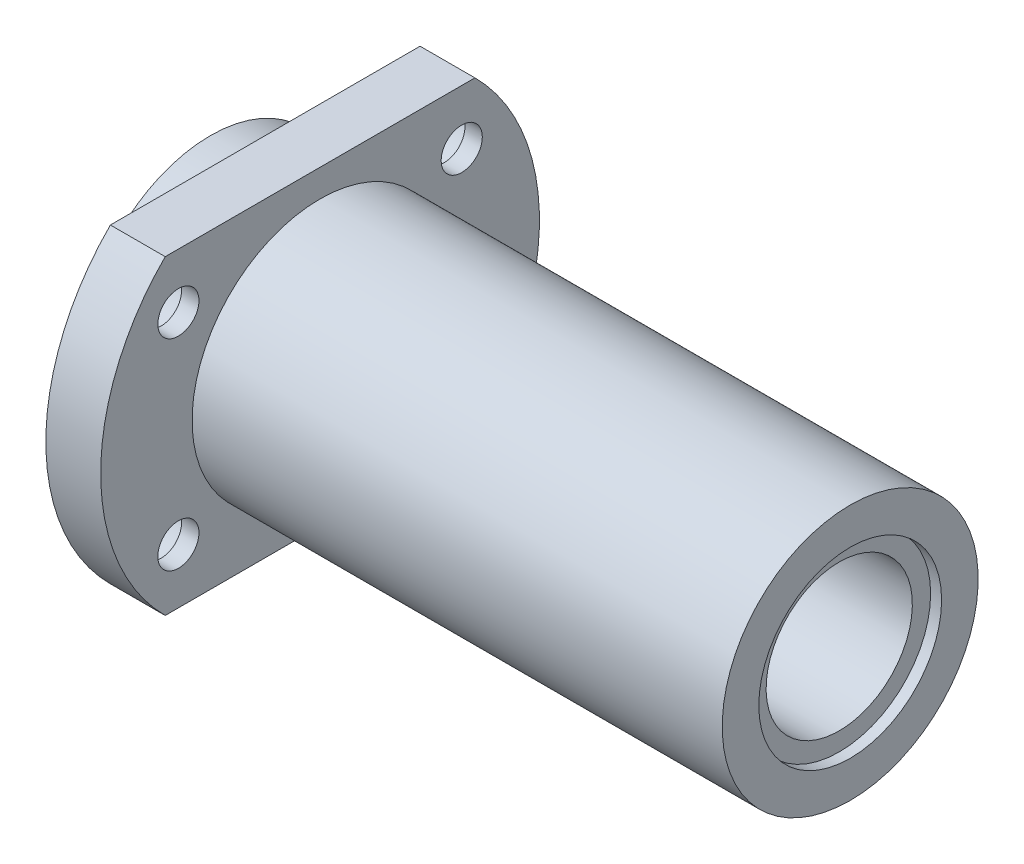
from build123d import *

# Parameters (mm, degrees)
SKETCH_4_R          = 2.25
CUT_EXTRUDE_1_DEPTH = 73.443081105
SKETCH_5_R          = 3.75
CUT_EXTRUDE_4_DEPTH = 4.1
CUT_EXTRUDE_3_DEPTH = 73.443081105


with BuildPart() as part:
    # 草图1 → 旋转1 (revolve)
    with BuildSketch(Plane.XY):
        Polygon((12, 24), (6, 24), (6, 14), (0, 14), (0, 10), (1.2, 10), (1.2, 8), (68.8, 8), (68.8, 10), (70, 10), (70, 14), (12, 14), align=None)
    revolve(axis=Axis((70, 0, 0), (-1, 0, 0)))

    # 草图4 → 切除-拉伸1 (cut, through all)
    with BuildSketch(Plane.ZY.offset(-6)):
        with Locations((15.5, 11)):
            Circle(SKETCH_4_R)
        with Locations((-15.5, -11)):
            Circle(SKETCH_4_R)
        with Locations((-15.5, 11)):
            Circle(SKETCH_4_R)
        with Locations((15.5, -11)):
            Circle(SKETCH_4_R)
    extrude(amount=-CUT_EXTRUDE_1_DEPTH, mode=Mode.SUBTRACT)

    # 草图5 → 切除-拉伸4 (cut)
    with BuildSketch(Plane.ZY.offset(-6)):
        with Locations((15.5, 11)):
            Circle(SKETCH_5_R)
        with Locations((-15.5, 11)):
            Circle(SKETCH_5_R)
        with Locations((-15.5, -11)):
            Circle(SKETCH_5_R)
        with Locations((15.5, -11)):
            Circle(SKETCH_5_R)
    extrude(amount=-CUT_EXTRUDE_4_DEPTH, mode=Mode.SUBTRACT)

    # 草图7 → 切除-拉伸3 (cut, through all)
    with BuildSketch(Plane.ZY.offset(-6)):
        with BuildLine():
            ThreePointArc((16.941074346, 17), (0, 24), (-16.941074346, 17))
            Line((-16.941074346, 17), (16.941074346, 17))
        make_face()
        with BuildLine():
            Line((16.941074346, -17), (-16.941074346, -17))
            ThreePointArc((-16.941074346, -17), (0, -24), (16.941074346, -17))
        make_face()
    extrude(amount=-CUT_EXTRUDE_3_DEPTH, mode=Mode.SUBTRACT)


solid = part.part
